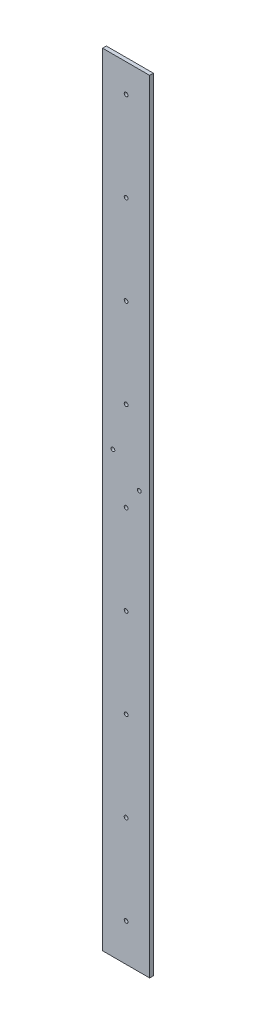
from build123d import *

# Parameters (mm, degrees)
SKETCH2_W           = 50
SKETCH2_H           = 900
BOSS_EXTRUDE1_DEPTH = 4
CUT_EXTRUDE1_REACH  = 6
SKETCH3_W           = 50
SKETCH3_H           = 70
SKETCH4_R           = 2
CUT_EXTRUDE4_DEPTH  = 5


with BuildPart() as part:
    # Sketch2 → Boss-Extrude1 (new body)
    with BuildSketch(Plane.XY):
        with Locations((0.371961745, 0.278971309)):
            Rectangle(SKETCH2_W, SKETCH2_H)
    extrude(amount=BOSS_EXTRUDE1_DEPTH)

    # Sketch3 → Cut-Extrude1 (cut, up to next)
    with BuildSketch(Plane.XY.offset(4), mode=Mode.PRIVATE) as cut_extrude1_sk1:
        with Locations((0.371961745, -414.721028691)):
            Rectangle(SKETCH3_W, SKETCH3_H)
    cut_extrude1_tool1 = extrude(cut_extrude1_sk1.sketch, amount=-CUT_EXTRUDE1_REACH, mode=Mode.PRIVATE) & part.part
    add(cut_extrude1_tool1.solids().sort_by_distance((0.371962, -414.721029, 4))[0], mode=Mode.SUBTRACT)

    # Sketch4 → Cut-Extrude4 (cut, through all)
    with BuildSketch(Plane(origin=(0, 0, 0), x_dir=(-1, 0, 0), z_dir=(0, 0, -1))):
        with Locations((13.628038255, 86.927507875)):
            Circle(SKETCH4_R)
        with Locations((12.128038255, 485.278971308)):
            Circle(SKETCH4_R)
        with Locations((-0.371961745, 500.278971309)):
            Circle(SKETCH4_R)
        with Locations((-0.371961745, 470.278971308)):
            Circle(SKETCH4_R)
        with Locations((-0.371961745, -244.721028692)):
            Circle(SKETCH4_R)
        with Locations((-0.371961745, -149.721028692)):
            Circle(SKETCH4_R)
        with Locations((-0.371961745, -54.721028692)):
            Circle(SKETCH4_R)
        with Locations((-0.371961745, 40.278971308)):
            Circle(SKETCH4_R)
        with Locations((-0.371961745, 135.278971308)):
            Circle(SKETCH4_R)
        with Locations((-0.371961745, 230.278971308)):
            Circle(SKETCH4_R)
        with Locations((-0.371961745, 325.278971308)):
            Circle(SKETCH4_R)
        with Locations((-0.371961745, 420.278971308)):
            Circle(SKETCH4_R)
        with Locations((-0.371961745, -339.721028692)):
            Circle(SKETCH4_R)
        with Locations((-14.371961745, 62.799089294)):
            Circle(SKETCH4_R)
    extrude(amount=-CUT_EXTRUDE4_DEPTH, mode=Mode.SUBTRACT)


solid = part.part
